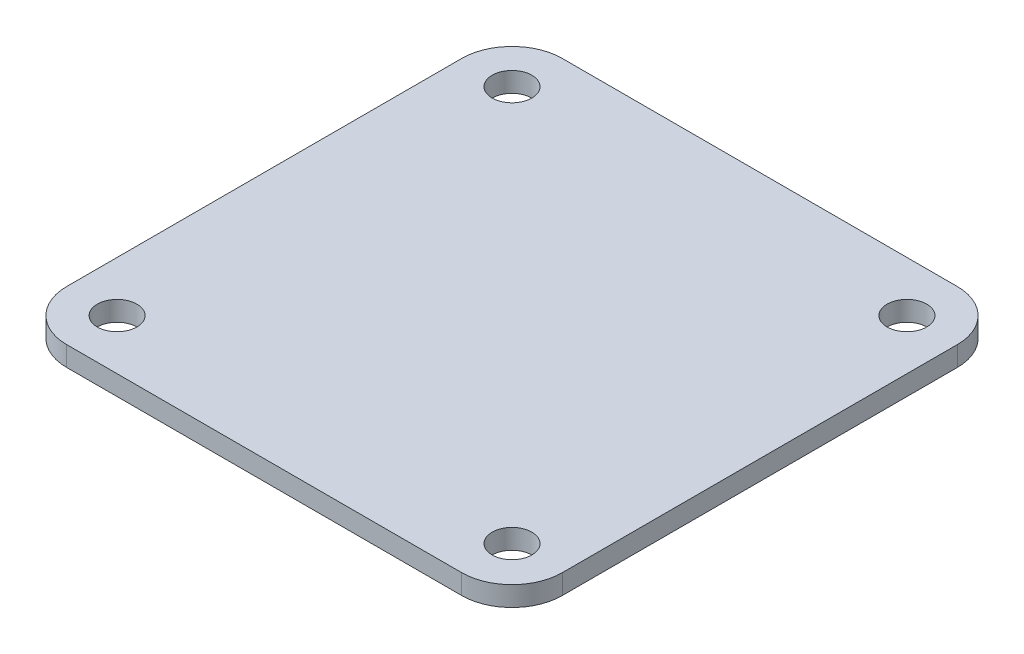
from build123d import *

# Parameters (mm, degrees)
SKETCH1_R           = 1
BOSS_EXTRUDE1_DEPTH = 1


with BuildPart() as part:
    # Sketch1 → Boss-Extrude1 (new body)
    with BuildSketch(Plane(origin=(0, 0, 0), x_dir=(1, 0, 0), z_dir=(0, 1, 0))):
        with BuildLine():
            Line((-9.96, -12.5), (9.96, -12.5))
            ThreePointArc((9.96, -12.5), (11.756051224, -11.756051224), (12.5, -9.96))
            Line((12.5, -9.96), (12.5, 9.96))
            ThreePointArc((12.5, 9.96), (11.756051224, 11.756051224), (9.96, 12.5))
            Line((9.96, 12.5), (-9.96, 12.5))
            ThreePointArc((-9.96, 12.5), (-11.756051224, 11.756051224), (-12.5, 9.96))
            Line((-12.5, 9.96), (-12.5, -9.96))
            ThreePointArc((-12.5, -9.96), (-11.756051224, -11.756051224), (-9.96, -12.5))
        make_face()
        with Locations((-10, 10)):
            Circle(SKETCH1_R, mode=Mode.SUBTRACT)
        with Locations((9.96, 9.96)):
            Circle(SKETCH1_R, mode=Mode.SUBTRACT)
        with Locations((9.96, -9.96)):
            Circle(SKETCH1_R, mode=Mode.SUBTRACT)
        with Locations((-9.96, -9.96)):
            Circle(SKETCH1_R, mode=Mode.SUBTRACT)
    extrude(amount=BOSS_EXTRUDE1_DEPTH)


solid = part.part
